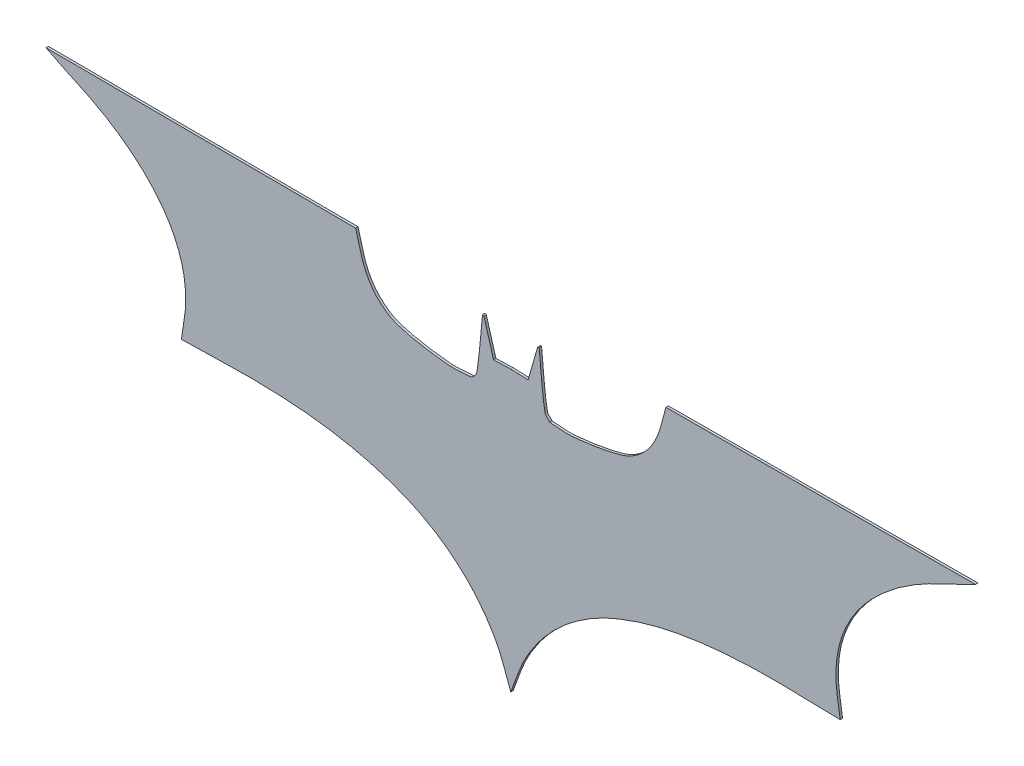
from build123d import *

# Parameters (mm, degrees)
BOSS_EXTRUDE1_DEPTH = 5


with BuildPart() as part:
    # Sketch1 → Boss-Extrude1 (new body)
    with BuildSketch(Plane.XY):
        with BuildLine():
            Line((24, 709), (669, 706))
            add(Edge.make_bspline(
                [(669, 706), (675.666666667, 684), (679.428701482, 660.900590641), (689, 640), (695.969834723, 624.780156829), (705.739306899, 610.397264009), (718, 599), (729.933025136, 587.907328746), (744.406789282, 578.721887753), (760, 574), (792.415406398, 564.184067077), (826.319518567, 559.568792735), (860, 556), (876.918355897, 554.207326527), (894, 557.333333333), (911, 558)],
                knots=[0, 0, 0, 0, 1, 1, 1, 2, 2, 2, 3, 3, 3, 4, 4, 4, 5, 5, 5, 5], degree=3))
            add(Edge.make_bspline(
                [(911, 558), (914.333333333, 562.333333333), (920.044950295, 565.616992574), (921, 571), (927.501236666, 607.643333934), (929, 645), (933, 682)],
                knots=[0, 0, 0, 0, 1, 1, 1, 2, 2, 2, 2], degree=3))
            Line((933, 682), (936, 681))
            Line((936, 681), (956, 612))
            Line((956, 612), (992, 613.384615385))
            Line((992, 613.384615385), (1028, 612))
            Line((1028, 612), (1048, 681))
            Line((1048, 681), (1051, 682))
            add(Edge.make_bspline(
                [(1073, 558), (1069.666666667, 562.333333333), (1063.955049705, 565.616992574), (1063, 571), (1056.498763334, 607.643333934), (1055, 645), (1051, 682)],
                knots=[0, 0, 0, 0, 1, 1, 1, 2, 2, 2, 2], degree=3))
            add(Edge.make_bspline(
                [(1315, 706), (1308.333333333, 684), (1304.571298518, 660.900590641), (1295, 640), (1288.030165277, 624.780156829), (1278.260693101, 610.397264009), (1266, 599), (1254.066974864, 587.907328746), (1239.593210718, 578.721887753), (1224, 574), (1191.584593602, 564.184067077), (1157.680481433, 559.568792735), (1124, 556), (1107.081644103, 554.207326527), (1090, 557.333333333), (1073, 558)],
                knots=[0, 0, 0, 0, 1, 1, 1, 2, 2, 2, 3, 3, 3, 4, 4, 4, 5, 5, 5, 5], degree=3))
            Line((1315, 706), (1960, 709))
            add(Edge.make_bspline(
                [(1678, 324), (1675, 349.333333333), (1668.822849088, 374.490268615), (1669, 400), (1669.159096537, 422.909901291), (1672.147807979, 446.138244503), (1679, 468), (1686.312497291, 491.3303485), (1697.326697601, 513.731339973), (1711, 534), (1725.923731153, 556.122236767), (1744.14158259, 576.174333979), (1764, 594), (1786.723866899, 614.397801783), (1811.70220913, 632.479992274), (1838, 648), (1877.156274729, 671.108621152), (1919.967870956, 687.444238207), (1960, 709)],
                knots=[0, 0, 0, 0, 1, 1, 1, 2, 2, 2, 3, 3, 3, 4, 4, 4, 5, 5, 5, 6, 6, 6, 6], degree=3))
            add(Edge.make_bspline(
                [(992, 31), (1002, 56), (1009.285049341, 82.265425436), (1022, 106), (1034.444126862, 129.229036809), (1049.658687828, 151.157537033), (1067, 171), (1084.544060771, 191.074454151), (1104.459789535, 209.290222443), (1126, 225), (1149.049716149, 241.810695237), (1173.8872173, 256.510375612), (1200, 268), (1232.51480495, 282.306514178), (1266.457812512, 293.709875003), (1301, 302), (1341.711440841, 311.770745802), (1383.293762207, 318.328676251), (1425, 322), (1479.140330002, 326.76587412), (1533.678564836, 327.75230436), (1588, 326), (1617.991806073, 325.032522385), (1648, 324.666666667), (1678, 324)],
                knots=[0, 0, 0, 0, 1, 1, 1, 2, 2, 2, 3, 3, 3, 4, 4, 4, 5, 5, 5, 6, 6, 6, 7, 7, 7, 8, 8, 8, 8], degree=3))
            add(Edge.make_bspline(
                [(992, 31), (982, 56), (974.714950659, 82.265425436), (962, 106), (949.555873138, 129.229036809), (934.341312172, 151.157537033), (917, 171), (899.455939229, 191.074454151), (879.540210465, 209.290222443), (858, 225), (834.950283851, 241.810695237), (810.1127827, 256.510375612), (784, 268), (751.48519505, 282.306514178), (717.542187488, 293.709875003), (683, 302), (642.288559159, 311.770745802), (600.706237793, 318.328676251), (559, 322), (504.859669998, 326.76587412), (450.321435164, 327.75230436), (396, 326), (366.008193927, 325.032522385), (336, 324.666666667), (306, 324)],
                knots=[0, 0, 0, 0, 1, 1, 1, 2, 2, 2, 3, 3, 3, 4, 4, 4, 5, 5, 5, 6, 6, 6, 7, 7, 7, 8, 8, 8, 8], degree=3))
            add(Edge.make_bspline(
                [(306, 324), (309, 349.333333333), (315.177150912, 374.490268615), (315, 400), (314.840903463, 422.909901291), (311.852192021, 446.138244503), (305, 468), (297.687502709, 491.3303485), (286.673302399, 513.731339973), (273, 534), (258.076268847, 556.122236767), (239.85841741, 576.174333979), (220, 594), (197.276133101, 614.397801783), (172.29779087, 632.479992274), (146, 648), (106.843725271, 671.108621152), (64.032129044, 687.444238207), (24, 709)],
                knots=[0, 0, 0, 0, 1, 1, 1, 2, 2, 2, 3, 3, 3, 4, 4, 4, 5, 5, 5, 6, 6, 6, 6], degree=3))
        make_face()
    extrude(amount=BOSS_EXTRUDE1_DEPTH)


solid = part.part
